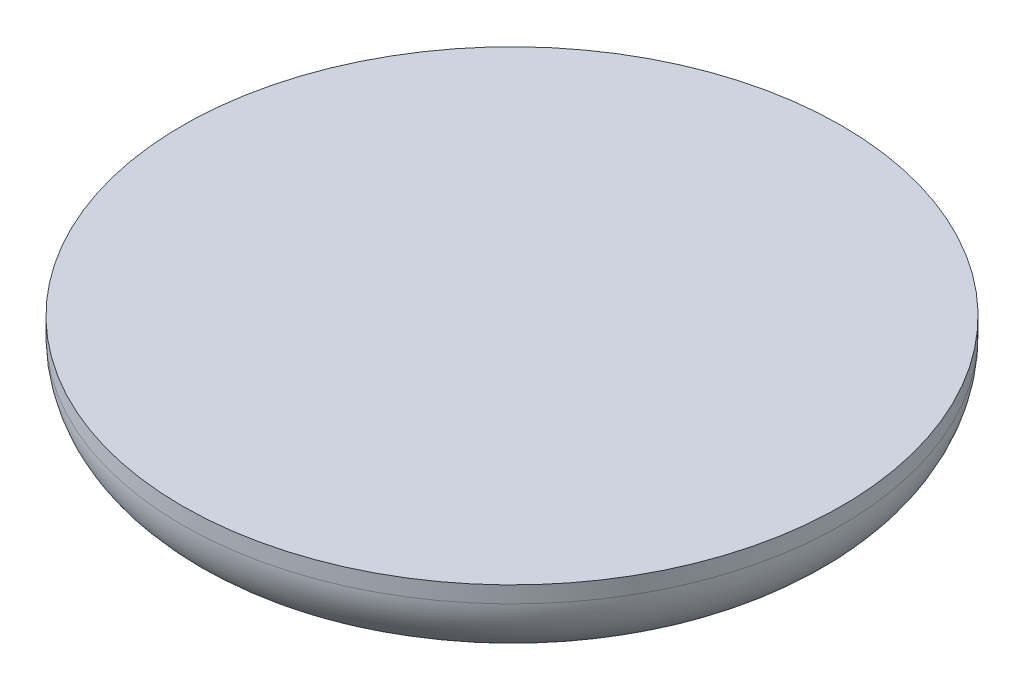
from build123d import *

# Parameters (mm, degrees)
SKETCH1_R           = 20
BOSS_EXTRUDE1_DEPTH = 5
FILLET1_R           = 4


with BuildPart() as part:
    # Sketch1 → Boss-Extrude1 (new body)
    with BuildSketch(Plane(origin=(0, 0, 0), x_dir=(1, 0, 0), z_dir=(0, 1, 0))):
        Circle(SKETCH1_R)
    extrude(amount=BOSS_EXTRUDE1_DEPTH)

    # Fillet1
    fillet1_edges = [part.edges().sort_by_distance(p)[0] for p in [
        (-20, 0, 0),
    ]]
    fillet(fillet1_edges, radius=FILLET1_R)


solid = part.part
